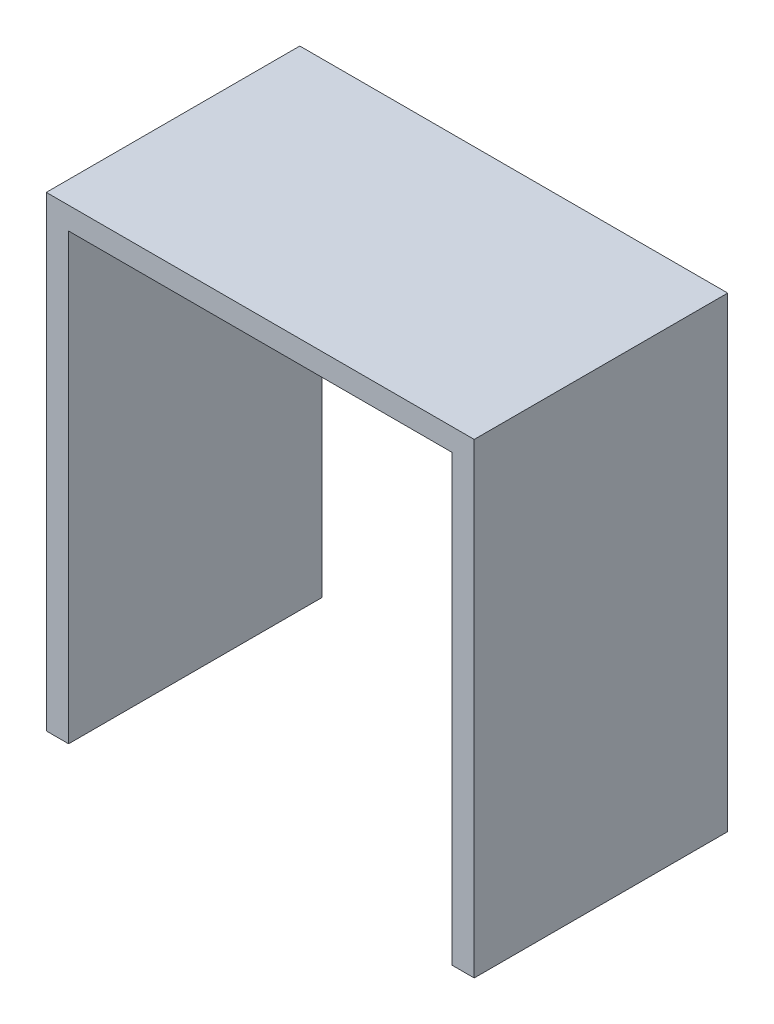
from build123d import *

# Parameters (mm, degrees)
BOSS_EXTRUDE1_DEPTH = 25


with BuildPart() as part:
    # Sketch1 → Boss-Extrude1 (new body)
    with BuildSketch(Plane.XY):
        Polygon((0, 0), (0, 46), (42.2, 46), (42.2, 0), (40, 0), (40, 43.8), (2.2, 43.8), (2.2, 0), align=None)
    extrude(amount=BOSS_EXTRUDE1_DEPTH)


solid = part.part
